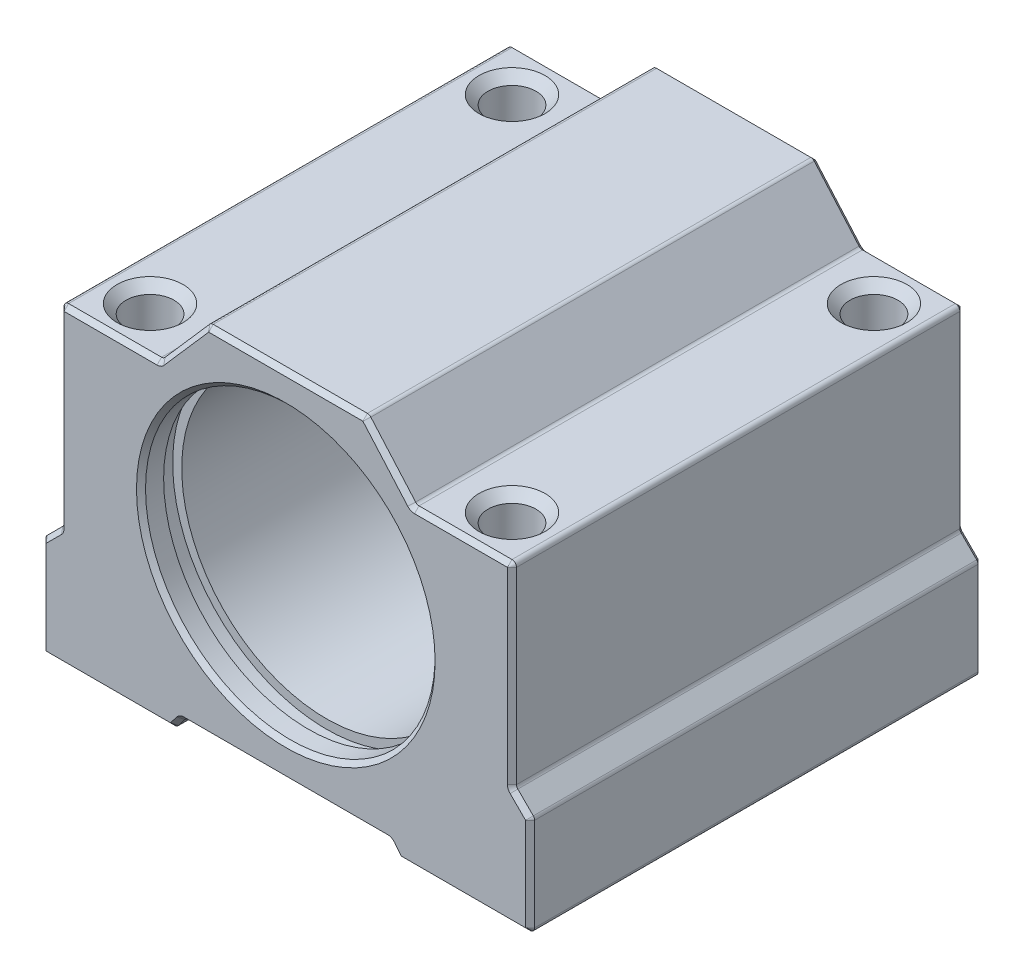
from build123d import *

# Parameters (mm, degrees)
SKETCH_1_W          = 50
SKETCH_1_H          = 40.5
EXTRUDE_1_DEPTH     = 25
SKETCH_5_R          = 2.65
CUT_EXTRUDE_2_DEPTH = 41.5
CUT_EXTRUDE_3_REACH = 52
CUT_EXTRUDE_4_DEPTH = 51
EXTRUDE_2_DEPTH     = 50
CHAMFER_1_SIZE      = 1
SKETCH_9_R          = 3
M6X12_DEPTH         = 12
FILLET_1_R          = 0.5
CHAMFER_3_SIZE      = 0.5
CUT_EXTRUDE_6_REACH = 52
SKETCH_10_R         = 16
CHAMFER_4_SIZE      = 0.5
SKETCH_11_W         = 2
SKETCH_11_H         = 17


with BuildPart() as part:
    # Эскиз1 → Бобышка-Вытянуть1 (new body, symmetric)
    with BuildSketch(Plane.XY):
        Rectangle(SKETCH_1_W, SKETCH_1_H)
    extrude(amount=EXTRUDE_1_DEPTH, both=True)

    # Эскиз5 → Вырез-Вытянуть2 (cut, through all)
    with BuildSketch(Plane(origin=(0, 20.25, 0), x_dir=(1, 0, 0), z_dir=(0, 1, 0))):
        with Locations((-20, 20)):
            Circle(SKETCH_5_R)
        with Locations((20, 20)):
            Circle(SKETCH_5_R)
        with Locations((20, -20)):
            Circle(SKETCH_5_R)
        with Locations((-20, -20)):
            Circle(SKETCH_5_R)
    extrude(amount=-CUT_EXTRUDE_2_DEPTH, mode=Mode.SUBTRACT)

    # Эскиз6 → Вырез-Вытянуть3 (cut, up to next)
    with BuildSketch(Plane.XY.offset(25), mode=Mode.PRIVATE) as cut_extrude_3_sk1:
        Polygon((-25, 14.25), (-14, 14.25), (-8.75, 20.25), (-25, 20.25), align=None)
    cut_extrude_3_tool1 = extrude(cut_extrude_3_sk1.sketch, amount=-CUT_EXTRUDE_3_REACH, mode=Mode.PRIVATE) & part.part
    add(cut_extrude_3_tool1.solids().sort_by_distance((-18.103211, 17.442661, 25))[0], mode=Mode.SUBTRACT)
    # Эскиз6 → Вырез-Вытянуть3 (cut, up to next)
    with BuildSketch(Plane.XY.offset(25), mode=Mode.PRIVATE) as cut_extrude_3_sk2:
        Polygon((25, 20.25), (25, 14.25), (14, 14.25), (8.75, 20.25), align=None)
    cut_extrude_3_tool2 = extrude(cut_extrude_3_sk2.sketch, amount=-CUT_EXTRUDE_3_REACH, mode=Mode.PRIVATE) & part.part
    add(cut_extrude_3_tool2.solids().sort_by_distance((18.103211, 17.442661, 25))[0], mode=Mode.SUBTRACT)

    # Эскиз7 → Вырез-Вытянуть4 (cut, through all)
    with BuildSketch(Plane.XY.offset(25)):
        Polygon((-12.5, -20.25), (-11.5, -18.95), (11.5, -18.95), (12.5, -20.25), align=None)
    extrude(amount=-CUT_EXTRUDE_4_DEPTH, mode=Mode.SUBTRACT)

    # Эскиз8 → Бобышка-Вытянуть2 (add)
    with BuildSketch(Plane.XY.offset(25)):
        Polygon((25, -20.25), (27, -20.25), (27, -9.25), (25, -7.25), align=None)
        Polygon((-25, -20.25), (-25, -7.25), (-27, -9.25), (-27, -20.25), align=None)
    extrude(amount=-EXTRUDE_2_DEPTH)

    # Фаска1
    chamfer_1_edges = [part.edges().sort_by_distance(p)[0] for p in [
        (-22.65, -20.25, -20),
        (17.35, -20.25, -20),
        (17.35, -20.25, 20),
        (-22.65, -20.25, 20),
        (-22.65, 14.25, 20),
        (-22.65, 14.25, -20),
        (17.35, 14.25, 20),
        (17.35, 14.25, -20),
    ]]
    chamfer(chamfer_1_edges, length=CHAMFER_1_SIZE)

    # Эскиз9 → M6x12 (cut)
    with BuildSketch(Plane.XZ.offset(20.25)):
        with Locations((-20, 20)):
            Circle(SKETCH_9_R)
        with Locations((20, 20)):
            Circle(SKETCH_9_R)
        with Locations((20, -20)):
            Circle(SKETCH_9_R)
        with Locations((-20, -20)):
            Circle(SKETCH_9_R)
    extrude(amount=-M6X12_DEPTH, mode=Mode.SUBTRACT)

    # Скругление1
    fillet_1_edges = [part.edges().sort_by_distance(p)[0] for p in [
        (-25, -7.25, 0),
        (-27, -9.25, 0),
        (-27, -20.25, 0),
        (-12.5, -20.25, 0),
        (-11.5, -18.95, 0),
        (11.5, -18.95, 0),
        (12.5, -20.25, 0),
        (27, -20.25, 0),
        (27, -9.25, 0),
        (25, -7.25, 0),
        (-25, 14.25, 0),
        (-14, 14.25, 0),
        (-8.75, 20.25, 0),
        (8.75, 20.25, 0),
        (14, 14.25, 0),
        (25, 14.25, 0),
    ]]
    fillet(fillet_1_edges, radius=FILLET_1_R)

    # Фаска3
    chamfer_3_edges = [part.edges().sort_by_distance(p)[0] for p in [
        (-25, 3.353553391, -25),
        (-25, 3.353553391, 25),
        (-26, -8.25, -25),
        (-26, -8.25, 25),
        (-19.623100374, -20.25, 25),
        (-12, -19.6, 25),
        (0, -18.95, 25),
        (12, -19.6, 25),
        (19.623100374, -20.25, 25),
        (27, -14.603553391, 25),
        (26, -8.25, 25),
        (25, 3.353553391, 25),
        (19.363442057, 14.25, 25),
        (11.375, 17.25, 25),
        (0, 20.25, 25),
        (-11.375, 17.25, 25),
        (-19.363442057, 14.25, 25),
        (-27, -14.603553391, 25),
        (24.853553391, 14.103553391, 25),
        (8.729724028, 20.205316457, 25),
        (-8.729724028, 20.205316457, 25),
        (-24.853553391, 14.103553391, 25),
        (26.961939766, -9.265765065, 25),
        (26.853553391, -20.103553391, 25),
        (12.525324868, -20.198568663, 25),
        (-12.525324868, -20.198568663, 25),
        (-26.853553391, -20.103553391, 25),
        (-26.961939766, -9.265765065, 25),
        (-27, -14.603553391, -25),
        (-12, -19.6, -25),
        (-19.623100374, -20.25, -25),
        (-19.363442057, 14.25, -25),
        (-11.375, 17.25, -25),
        (0, 20.25, -25),
        (11.375, 17.25, -25),
        (19.363442057, 14.25, -25),
        (25, 3.353553391, -25),
        (26, -8.25, -25),
        (27, -14.603553391, -25),
        (19.623100374, -20.25, -25),
        (12, -19.6, -25),
        (0, -18.95, -25),
        (24.853553391, 14.103553391, -25),
        (8.729724028, 20.205316457, -25),
        (-8.729724028, 20.205316457, -25),
        (-24.853553391, 14.103553391, -25),
        (26.961939766, -9.265765065, -25),
        (26.853553391, -20.103553391, -25),
        (12.525324868, -20.198568663, -25),
        (-12.525324868, -20.198568663, -25),
        (-26.853553391, -20.103553391, -25),
        (-26.961939766, -9.265765065, -25),
        (-25.038060234, -7.234234935, 25),
        (-25.038060234, -7.234234935, -25),
        (-11.474675132, -19.001431337, 25),
        (-11.474675132, -19.001431337, -25),
        (11.474675132, -19.001431337, 25),
        (11.474675132, -19.001431337, -25),
        (25.038060234, -7.234234935, 25),
        (25.038060234, -7.234234935, -25),
        (-14.020275972, 14.294683543, 25),
        (-14.020275972, 14.294683543, -25),
        (14.020275972, 14.294683543, 25),
        (14.020275972, 14.294683543, -25),
    ]]
    chamfer(chamfer_3_edges, length=CHAMFER_3_SIZE)

    # Эскиз10 → Вырез-Вытянуть6 (cut, up to next)
    with BuildSketch(Plane.XY.offset(25), mode=Mode.PRIVATE) as cut_extrude_6_sk1:
        with Locations((0, 0.75)):
            Circle(SKETCH_10_R)
    cut_extrude_6_tool1 = extrude(cut_extrude_6_sk1.sketch, amount=-CUT_EXTRUDE_6_REACH, mode=Mode.PRIVATE) & part.part
    add(cut_extrude_6_tool1.solids().sort_by_distance((0, 0.75, 25))[0], mode=Mode.SUBTRACT)

    # Фаска4
    chamfer_4_edges = [part.edges().sort_by_distance(p)[0] for p in [
        (-16, 0.75, -25),
        (-16, 0.75, 25),
    ]]
    chamfer(chamfer_4_edges, length=CHAMFER_4_SIZE)

    # Эскиз11 → Вырез-Повернуть1 (revolve, cut)
    with BuildSketch(Plane(origin=(0, 0, 0), x_dir=(0, 0, -1), z_dir=(1, 0, 0))):
        with Locations((-21.5, 9.25)):
            Rectangle(SKETCH_11_W, SKETCH_11_H)
        with Locations((21.5, 9.25)):
            Rectangle(SKETCH_11_W, SKETCH_11_H)
    revolve(axis=Axis((0, 0.75, 25), (0, 0, -1)), mode=Mode.SUBTRACT)


solid = part.part
